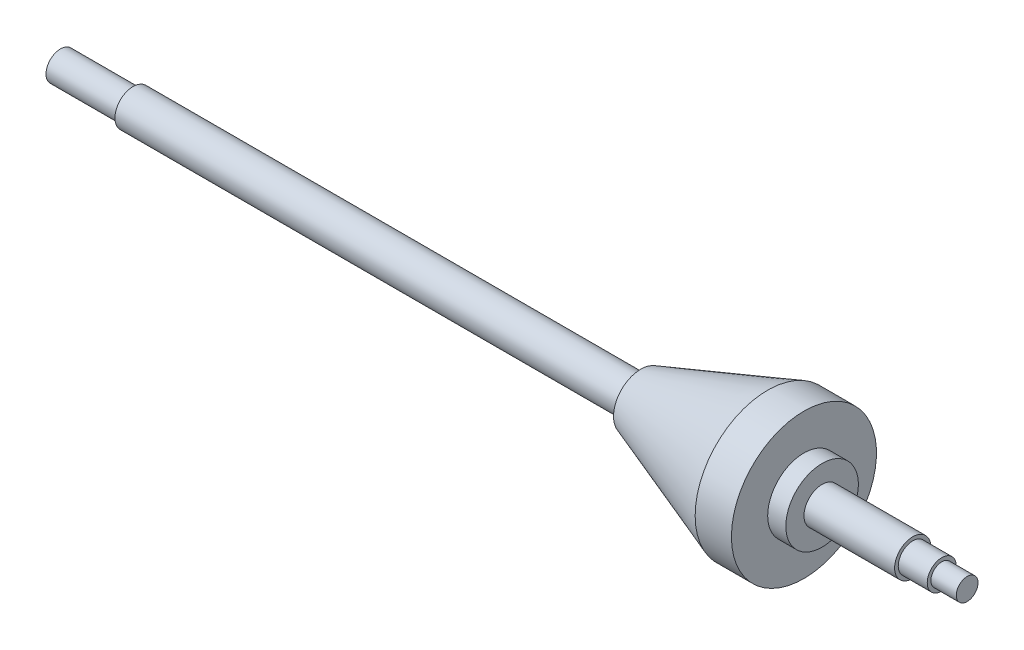
from build123d import *


with BuildPart() as part:
    # Sketch2 → Revolve6 (revolve)
    with BuildSketch(Plane.XY, mode=Mode.PRIVATE) as revolve6_sk:
        Polygon((0, 0), (0, 4), (20, 4), (20, 5), (130, 5), (160, 5), (160, 7.5), (195, 20), (205, 20), (205, 10), (210, 10), (210, 5), (235, 5), (235, 4), (243, 4), (243, 3), (250, 3), (250, 0), align=None)
    revolve(revolve6_sk.sketch.rotate(Axis((0, 0, 0), (1, 0, 0)), 90), axis=Axis((0, 0, 0), (1, 0, 0)))  # turned: the seam where the file's is


solid = part.part
